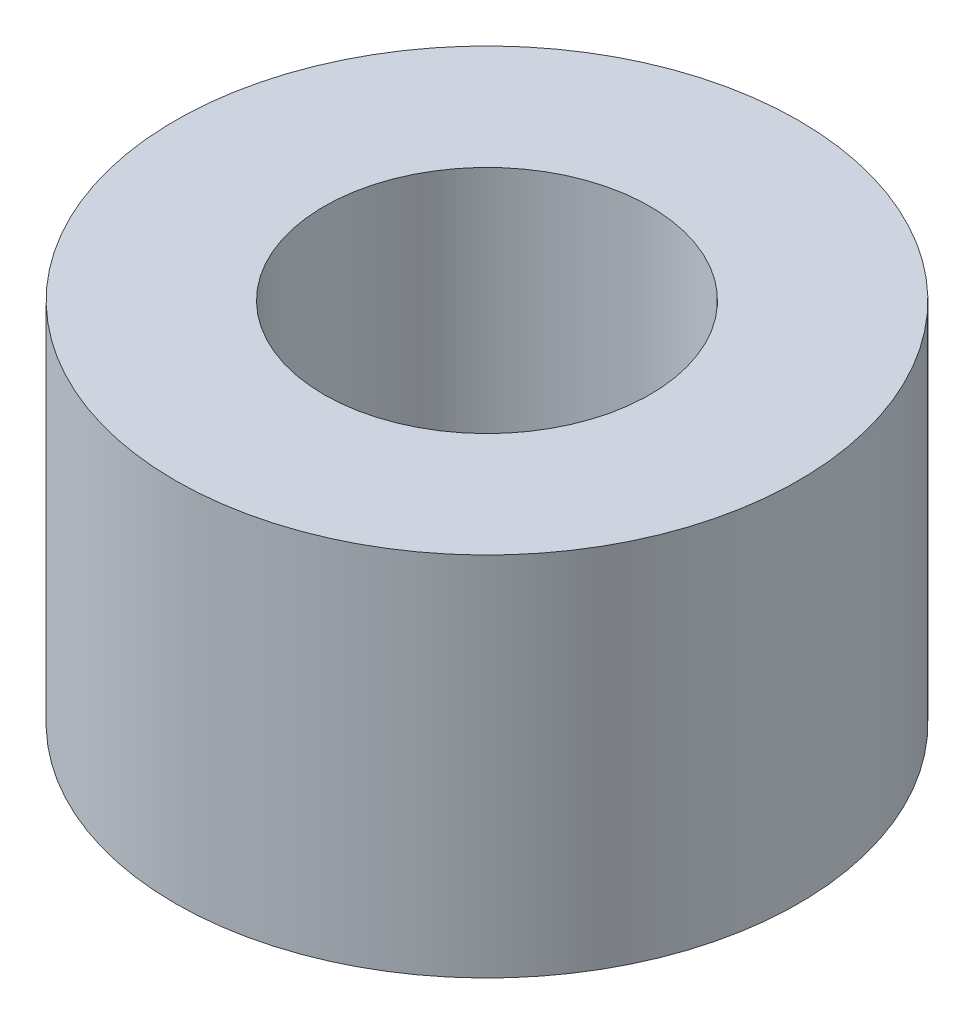
from build123d import *

# Parameters (mm, degrees)
SZKIC1_R                    = 4.255
SZKIC1_R_2                  = 2.225
DODANIE_WYCI_GNI_CIE1_DEPTH = 2.5


with BuildPart() as part:
    # Szkic1 → Dodanie-wyciągnięcie1 (new body, symmetric)
    with BuildSketch(Plane(origin=(0, 0, 0), x_dir=(1, 0, 0), z_dir=(0, 1, 0))):
        Circle(SZKIC1_R)
        Circle(SZKIC1_R_2, mode=Mode.SUBTRACT)
    extrude(amount=DODANIE_WYCI_GNI_CIE1_DEPTH, both=True)


solid = part.part
